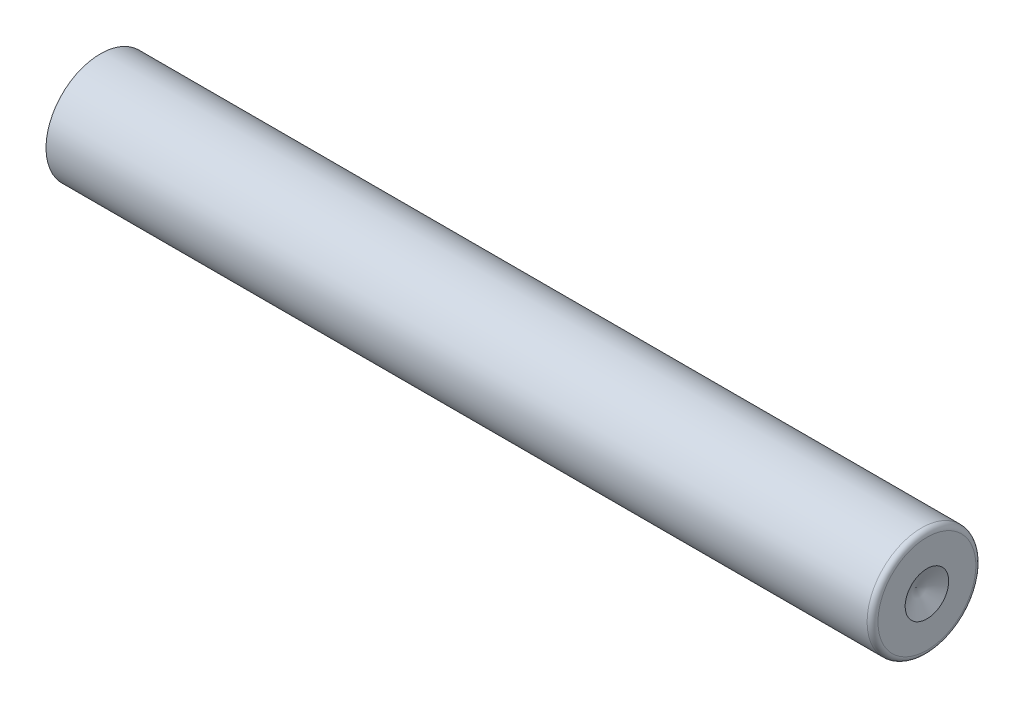
from build123d import *

# Parameters (mm, degrees)
CROQUIS1_W  = 38
CROQUIS1_H  = 2.5
REDONDEO1_R = 0.25


with BuildPart() as part:
    # Croquis1 → Revolución1 (revolve)
    with BuildSketch(Plane.XY):
        with Locations((19, 1.25)):
            Rectangle(CROQUIS1_W, CROQUIS1_H)
    revolve(axis=Axis((0, 0, 0), (1, 0, 0)))

    # Redondeo1
    redondeo1_edges = [part.edges().sort_by_distance(p)[0] for p in [
        (38, -2.5, 0),
    ]]
    fillet(redondeo1_edges, radius=REDONDEO1_R)

    # Croquis3 → Cortar-Revolución1 (revolve, cut)
    with BuildSketch(Plane.XY):
        Polygon((38, 0), (37.5, 0), (38, 1), align=None)
    revolve(axis=Axis((38, 0, 0), (-1, 0, 0)), mode=Mode.SUBTRACT)


solid = part.part
